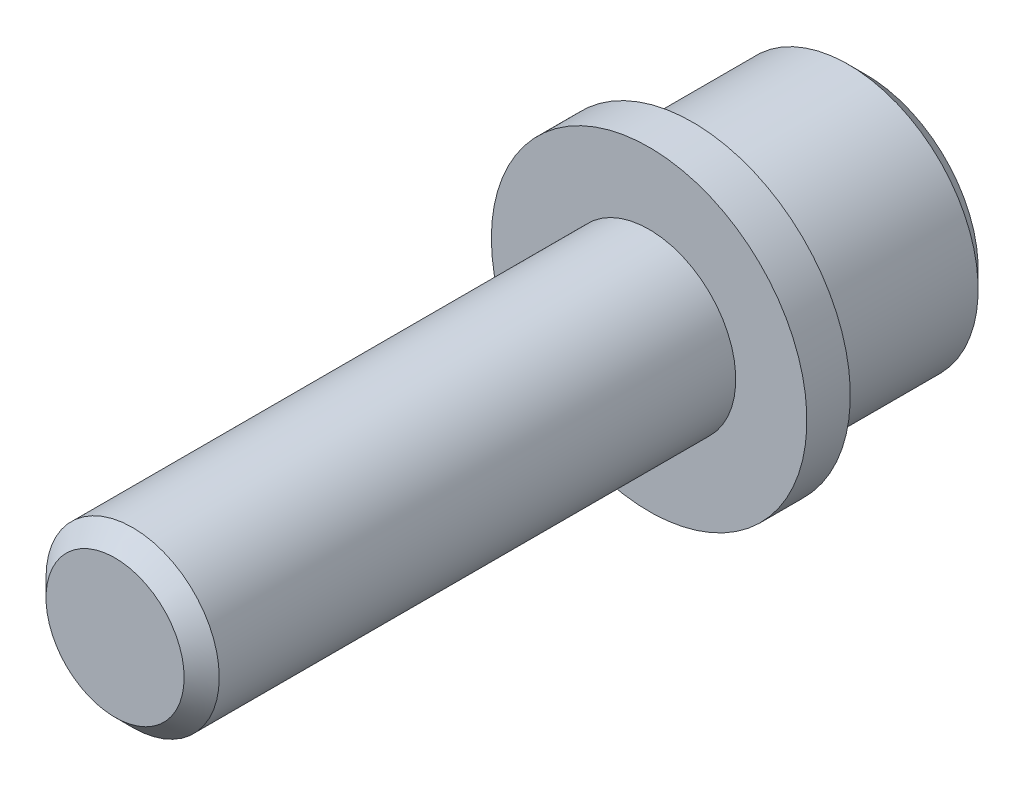
from build123d import *

# Parameters (mm, degrees)
CUT_EXTRUDE1_DEPTH = 6.35
CHAMFER1_SIZE      = 0.9652
CHAMFER2_SIZE      = 0.9652


with BuildPart() as part:
    # Sketch1 → Revolve1 (revolve)
    with BuildSketch(Plane(origin=(0, 0, 0), x_dir=(1, 0, 0), z_dir=(0, 1, 0))):
        Polygon((0, 52.830247514), (0, 11.555247514), (-4.7625, 11.555247514), (-4.7625, 40.917647514), (-8.6741, 40.917647514), (-8.6741, 43.305247514), (-7.14375, 43.305247514), (-7.14375, 52.830247514), align=None)
    revolve(axis=Axis((0, 0, -86.603340611), (0, 0, 1)))

    # Sketch2 → Cut-Extrude1 (cut)
    with BuildSketch(Plane(origin=(0, 0, -52.830247514), x_dir=(-1, 0, 0), z_dir=(0, 0, -1))):
        Polygon((2.27302801, 3.937), (-2.27302801, 3.937), (-4.54605602, 0), (-2.27302801, -3.937), (2.27302801, -3.937), (4.54605602, 0), align=None)
    extrude(amount=-CUT_EXTRUDE1_DEPTH, mode=Mode.SUBTRACT)

    # Chamfer1
    chamfer1_edges = [part.edges().sort_by_distance(p)[0] for p in [
        (4.7625, 0, -11.555247514),
    ]]
    chamfer(chamfer1_edges, length=CHAMFER1_SIZE)

    # Chamfer2
    chamfer2_edges = [part.edges().sort_by_distance(p)[0] for p in [
        (7.14375, 0, -52.830247514),
    ]]
    chamfer(chamfer2_edges, length=CHAMFER2_SIZE)


solid = part.part
